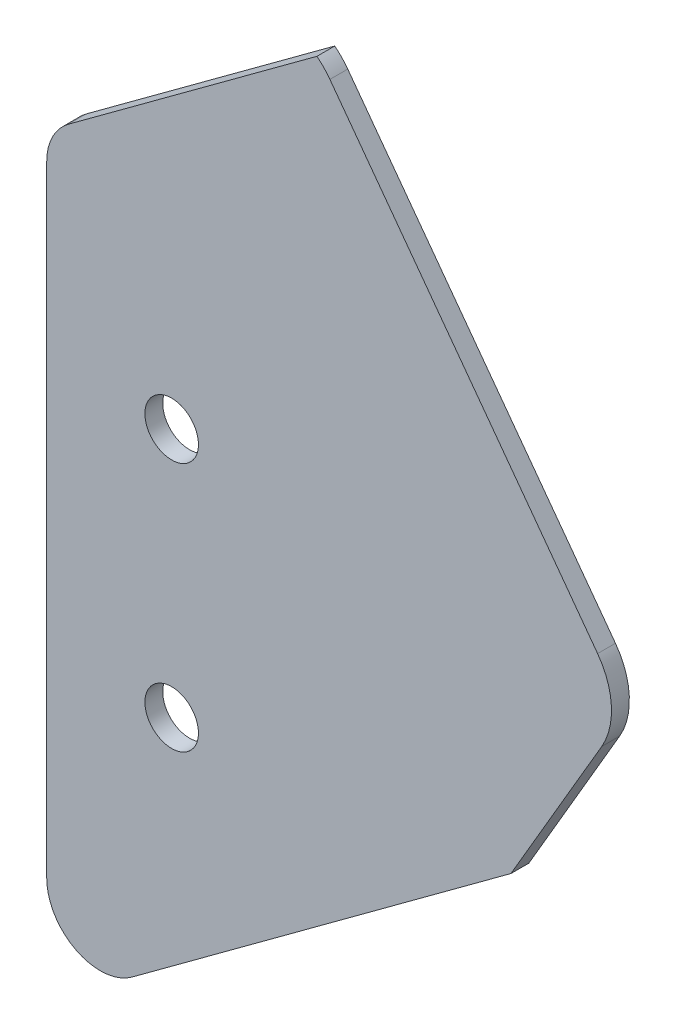
from build123d import *

# Parameters (mm, degrees)
SKETCH1_R           = 4.7625
BOSS_EXTRUDE1_DEPTH = 3.175


with BuildPart() as part:
    # Sketch1 → Boss-Extrude1 (new body)
    with BuildSketch(Plane.XY):
        with BuildLine():
            Line((111.332808166, 350.586079181), (63.710529936, 415.237184501))
            ThreePointArc((63.710529936, 415.237184501), (62.634536999, 416.513021087), (61.400531956, 417.636743182))
            Line((61.400531956, 417.636743182), (17.210961523, 385.086518286))
            ThreePointArc((17.210961523, 385.086518286), (14.359037805, 381.713915243), (13.335, 377.417490362))
            Line((13.335, 377.417490362), (13.335, 267.002909993))
            ThreePointArc((13.335, 267.002909993), (18.563575119, 258.501947797), (28.509038477, 259.333882069))
            Line((28.509038477, 259.333882069), (95.90843461, 308.980562961))
            Line((95.90843461, 308.980562961), (112.073002649, 336.647282747))
            ThreePointArc((112.073002649, 336.647282747), (113.789568713, 343.727489431), (111.332808166, 350.586079181))
        make_face()
        with Locations((35.56, 302.837639338)):
            Circle(SKETCH1_R, mode=Mode.SUBTRACT)
        with Locations((35.56, 347.287639338)):
            Circle(SKETCH1_R, mode=Mode.SUBTRACT)
    extrude(amount=BOSS_EXTRUDE1_DEPTH)


solid = part.part
